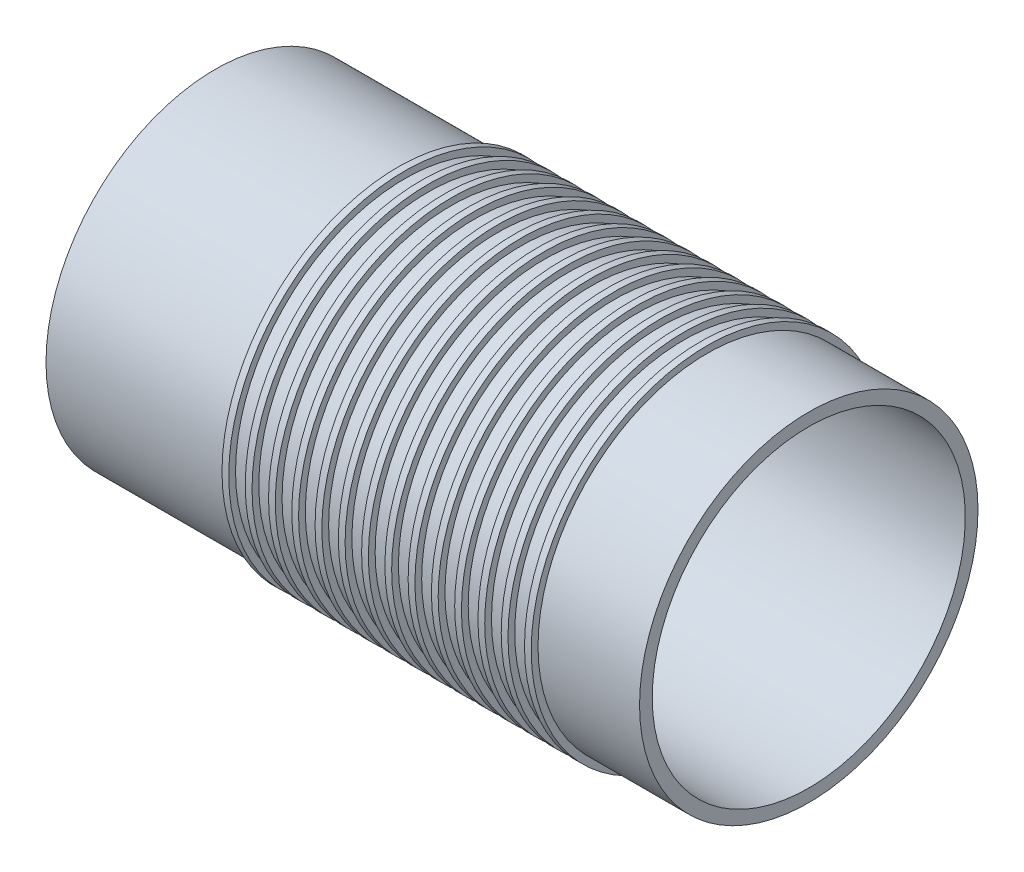
from build123d import *


with BuildPart() as part:
    # Sketch1 → Revolve1 (revolve)
    with BuildSketch(Plane.XY):
        Polygon((-35.075, 18.5), (35.075, 18.5), (35.075, 20), (23.075, 20), (23.075, 20.8), (22.275, 20.8), (22.275, 20), (20.325, 20), (20.325, 20.8), (19.525, 20.8), (19.525, 20), (17.575, 20), (17.575, 20.8), (16.775, 20.8), (16.775, 20), (14.825, 20), (14.825, 20.8), (14.025, 20.8), (14.025, 20), (12.075, 20), (12.075, 20.8), (11.275, 20.8), (11.275, 20), (9.325, 20), (9.325, 20.8), (8.525, 20.8), (8.525, 20), (6.575, 20), (6.575, 20.8), (5.775, 20.8), (5.775, 20), (3.825, 20), (3.825, 20.8), (3.025, 20.8), (3.025, 20), (1.075, 20), (1.075, 20.8), (0.275, 20.8), (0.275, 20), (-1.675, 20), (-1.675, 20.8), (-2.475, 20.8), (-2.475, 20), (-4.425, 20), (-4.425, 20.8), (-5.225, 20.8), (-5.225, 20), (-7.175, 20), (-7.175, 20.8), (-7.975, 20.8), (-7.975, 20), (-9.925, 20), (-9.925, 20.8), (-10.725, 20.8), (-10.725, 20), (-12.675, 20), (-12.675, 20.8), (-13.475, 20.8), (-13.475, 20), (-35.075, 20), align=None)
    revolve(axis=Axis((-100.187905083, 0, 0), (1, 0, 0)))


solid = part.part
